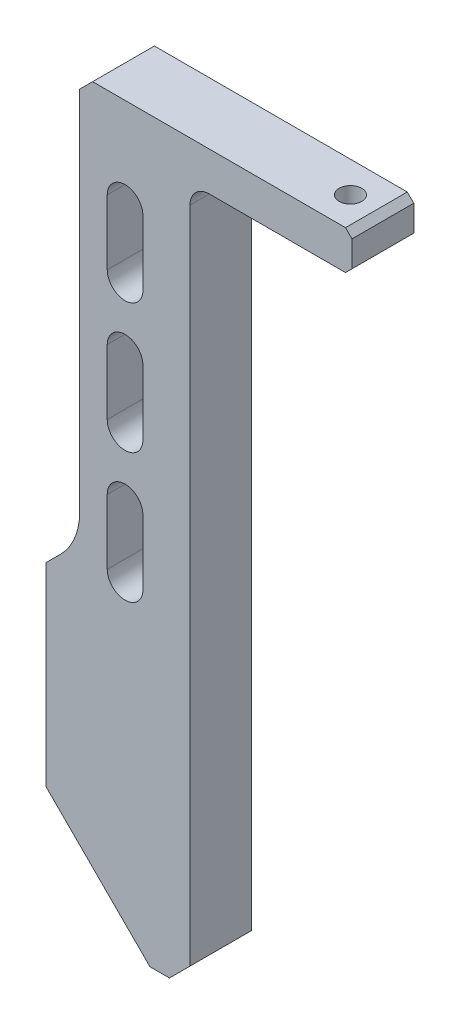
from build123d import *

# Parameters (mm, degrees)
BOSS_EXTRUDE1_DEPTH      = 4.7625
BOSS_EXTRUDE1_DEPTH_BACK = 4.7625
SKETCH2_R                = 1.75
CUT_EXTRUDE1_DEPTH       = 237.61909032
FILLET1_R                = 10
CHAMFER1_SIZE            = 2
CHAMFER2_SIZE            = 1
FILLET2_R                = 3


with BuildPart() as part:
    # Sketch1 → Boss-Extrude1 (new, two sides: drawn at the far end of the back side and taken through both)
    with BuildSketch(Plane.XY.offset(-BOSS_EXTRUDE1_DEPTH_BACK)):
        Polygon((-191.403805922, 11.396194078), (-207.403805922, 27.396194078), (-207.403805922, 57.396194078), (-202.247691321, 62.552308679), (-202.247691321, 125.192388155), (-160.247691321, 125.192388155), (-160.247691321, 119.192388155), (-185.247691321, 119.192388155), (-185.247691321, 14.552308679), (-188.403805922, 11.396194078), align=None)
        with BuildLine():
            Line((-192.497691321, 61.192388155), (-192.497691321, 71.192388155))
            ThreePointArc((-192.497691321, 71.192388155), (-195.247691321, 73.942388155), (-197.997691321, 71.192388155))
            Line((-197.997691321, 71.192388155), (-197.997691321, 61.192388155))
            ThreePointArc((-197.997691321, 61.192388155), (-195.247691321, 58.442388155), (-192.497691321, 61.192388155))
        make_face(mode=Mode.SUBTRACT)
        with BuildLine():
            Line((-192.497691321, 81.192388155), (-192.497691321, 91.192388155))
            ThreePointArc((-192.497691321, 91.192388155), (-195.247691321, 93.942388155), (-197.997691321, 91.192388155))
            Line((-197.997691321, 91.192388155), (-197.997691321, 81.192388155))
            ThreePointArc((-197.997691321, 81.192388155), (-195.247691321, 78.442388155), (-192.497691321, 81.192388155))
        make_face(mode=Mode.SUBTRACT)
        with BuildLine():
            Line((-192.497691321, 101.192388155), (-192.497691321, 111.192388155))
            ThreePointArc((-192.497691321, 111.192388155), (-195.247691321, 113.942388155), (-197.997691321, 111.192388155))
            Line((-197.997691321, 111.192388155), (-197.997691321, 101.192388155))
            ThreePointArc((-197.997691321, 101.192388155), (-195.247691321, 98.442388155), (-192.497691321, 101.192388155))
        make_face(mode=Mode.SUBTRACT)
    extrude(amount=BOSS_EXTRUDE1_DEPTH + BOSS_EXTRUDE1_DEPTH_BACK)

    # Sketch2 → Cut-Extrude1 (cut, through all)
    with BuildSketch(Plane(origin=(0, 125.192388155, 0), x_dir=(-1, 0, 0), z_dir=(0, 1, 0))):
        with Locations((165.247691321, 0)):
            Circle(SKETCH2_R)
    extrude(amount=-CUT_EXTRUDE1_DEPTH, mode=Mode.SUBTRACT)

    # Fillet1
    fillet1_edges = [part.edges().sort_by_distance(p)[0] for p in [
        (-202.247691321, 62.552308679, 0),
    ]]
    fillet(fillet1_edges, radius=FILLET1_R)

    # Chamfer1
    chamfer1_edges = [part.edges().sort_by_distance(p)[0] for p in [
        (-202.247691321, 125.192388155, 0),
    ]]
    chamfer(chamfer1_edges, length=CHAMFER1_SIZE)

    # Chamfer2
    chamfer2_edges = [part.edges().sort_by_distance(p)[0] for p in [
        (-160.247691321, 125.192388155, 0),
        (-160.247691321, 119.192388155, 0),
    ]]
    chamfer(chamfer2_edges, length=CHAMFER2_SIZE)

    # Fillet2
    fillet2_edges = [part.edges().sort_by_distance(p)[0] for p in [
        (-185.247691321, 119.192388155, 0),
    ]]
    fillet(fillet2_edges, radius=FILLET2_R)


solid = part.part
